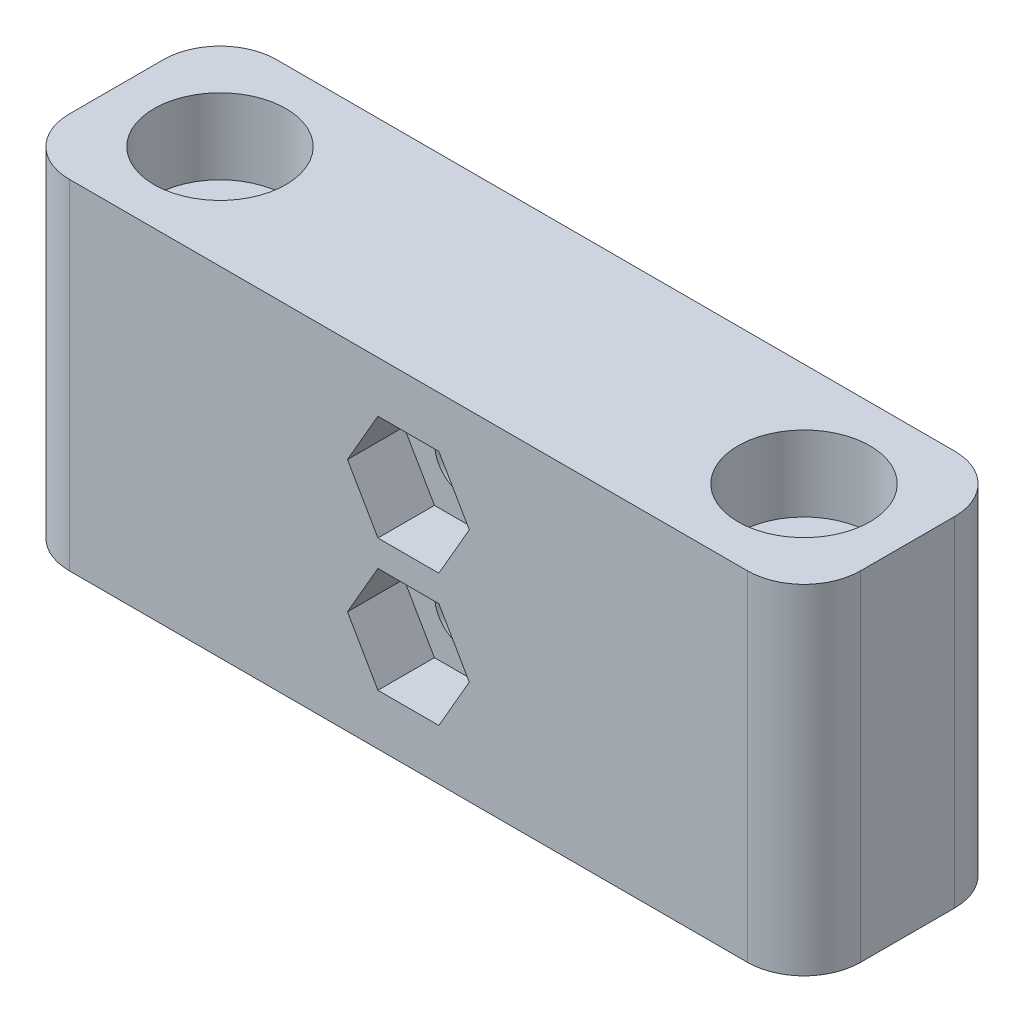
from build123d import *

# Parameters (mm, degrees)
SKETCH_1_W          = 42
SKETCH_1_H          = 11
SKETCH_1_R          = 1.6
EXTRUDE_1_DEPTH     = 18
FILLET_1_R          = 3
SKETCH_3_R          = 3.5
CUT_EXTRUDE_2_DEPTH = 4
SKETCH_4_R          = 1.6
CUT_EXTRUDE_3_DEPTH = 11
CUT_EXTRUDE_4_DEPTH = 3


with BuildPart() as part:
    # 스케치1 → 보스-돌출1 (new body)
    with BuildSketch(Plane(origin=(0, -13.749164409, 0), x_dir=(1, 0, 0), z_dir=(0, 1, 0))):
        with Locations((-11.155757596, -57.302460642)):
            Rectangle(SKETCH_1_W, SKETCH_1_H)
        with Locations((-26.655757596, -57.302460642)):
            Circle(SKETCH_1_R, mode=Mode.SUBTRACT)
        with Locations((4.344242404, -57.302460642)):
            Circle(SKETCH_1_R, mode=Mode.SUBTRACT)
    extrude(amount=EXTRUDE_1_DEPTH)

    # 필렛1
    fillet_1_edges = [part.edges().sort_by_distance(p)[0] for p in [
        (-32.155757596, -4.749164409, 51.802460642),
        (9.844242404, -4.749164409, 51.802460642),
        (9.844242404, -4.749164409, 62.802460642),
        (-32.155757596, -4.749164409, 62.802460642),
    ]]
    fillet(fillet_1_edges, radius=FILLET_1_R)

    # 스케치3 → 컷-돌출2 (cut)
    with BuildSketch(Plane(origin=(0, 4.250835591, 0), x_dir=(1, 0, 0), z_dir=(0, 1, 0))):
        with Locations((-26.655757596, -57.302460642)):
            Circle(SKETCH_3_R)
        with Locations((4.344242404, -57.302460642)):
            Circle(SKETCH_3_R)
    extrude(amount=-CUT_EXTRUDE_2_DEPTH, mode=Mode.SUBTRACT)

    # 스케치4 → 컷-돌출3 (cut)
    with BuildSketch(Plane(origin=(0, 0, 51.802460642), x_dir=(-1, 0, 0), z_dir=(0, 0, -1))):
        with Locations((11.155757596, -1.249164409)):
            Circle(SKETCH_4_R)
        with Locations((11.155757596, -8.249164409)):
            Circle(SKETCH_4_R)
    extrude(amount=-CUT_EXTRUDE_3_DEPTH, mode=Mode.SUBTRACT)

    # 스케치6 → 컷-돌출4 (cut)
    with BuildSketch(Plane.XY.offset(62.802460642)):
        Polygon((-7.922596089, -1.249164409), (-9.539176842, 1.550835591), (-12.77233835, 1.550835591), (-14.388919104, -1.249164409), (-12.77233835, -4.049164409), (-9.539176842, -4.049164409), align=None)
        Polygon((-7.922596089, -8.249164409), (-9.539176842, -5.449164409), (-12.77233835, -5.449164409), (-14.388919104, -8.249164409), (-12.77233835, -11.049164409), (-9.539176842, -11.049164409), align=None)
    extrude(amount=-CUT_EXTRUDE_4_DEPTH, mode=Mode.SUBTRACT)


solid = part.part
